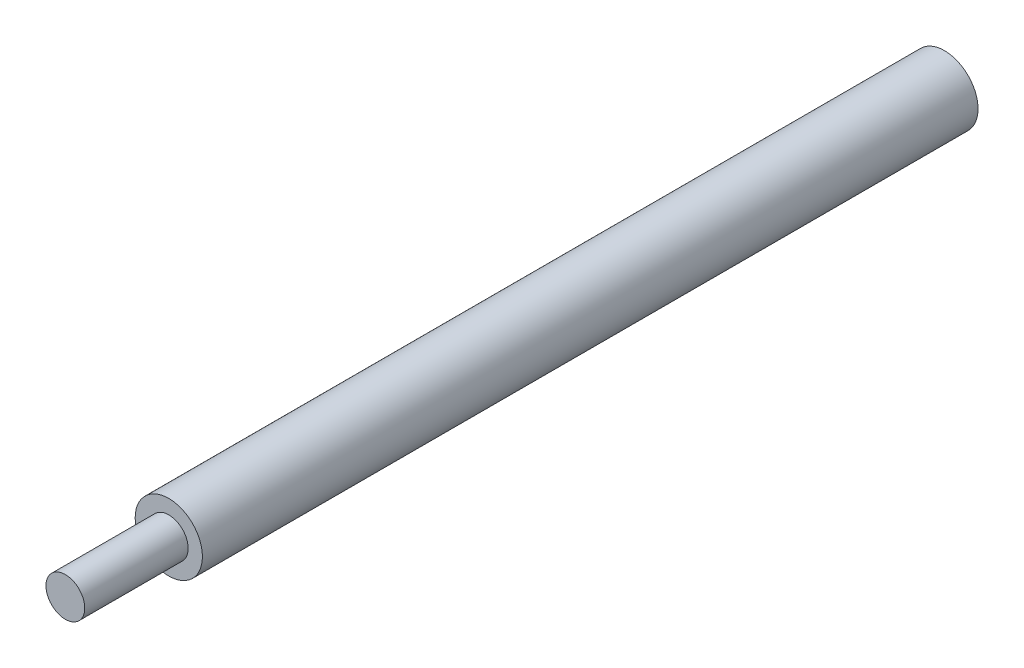
from build123d import *

# Parameters (mm, degrees)
SKETCH_1_R      = 1.5
EXTRUDE_1_DEPTH = 8
SKETCH_2_R      = 2.6
EXTRUDE_2_DEPTH = 60


with BuildPart() as part:
    # 草图1 → 凸台-拉伸1 (new body)
    with BuildSketch(Plane.XY):
        Circle(SKETCH_1_R)
    extrude(amount=EXTRUDE_1_DEPTH)

    # 草图2 → 凸台-拉伸2 (add)
    with BuildSketch(Plane(origin=(0, 0, 0), x_dir=(-1, 0, 0), z_dir=(0, 0, -1))):
        Circle(SKETCH_2_R)
    extrude(amount=EXTRUDE_2_DEPTH)


solid = part.part
